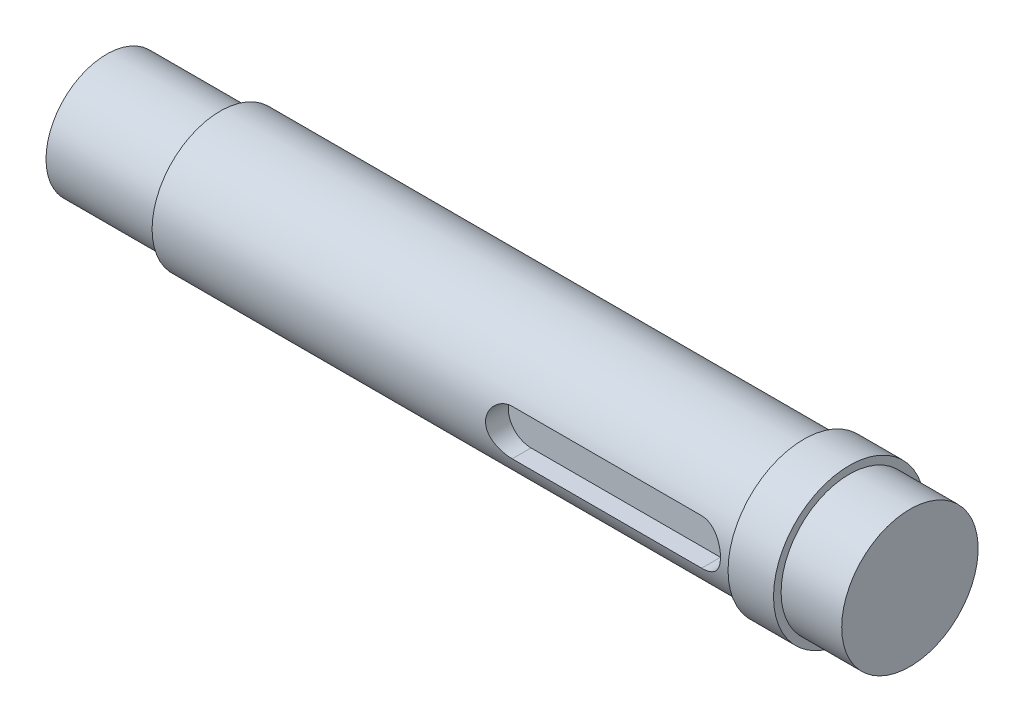
from build123d import *

# Parameters (mm, degrees)
CUT_EXTRUDE_2_DEPTH = 3


with BuildPart() as part:
    # 草图2 → 旋转1 (revolve)
    with BuildSketch(Plane(origin=(0, 0, 0), x_dir=(1, 0, 0), z_dir=(0, 1, 0))):
        Polygon((0, 0), (0, 8), (15, 8), (15, 9), (92, 9), (92, 10), (98, 10), (98, 9), (106, 9), (106, 0), align=None)
    revolve(axis=Axis((0, 0, 0), (1, 0, 0)))

    # 草图4 → 切除-拉伸2 (cut)
    with BuildSketch(Plane.XY.offset(9)):
        with BuildLine():
            Line((62, 3), (87, 3))
            ThreePointArc((87, 3), (90, 0), (87, -3))
            Line((87, -3), (62, -3))
            ThreePointArc((62, -3), (59, 0), (62, 3))
        make_face()
    extrude(amount=-CUT_EXTRUDE_2_DEPTH, mode=Mode.SUBTRACT)


solid = part.part
